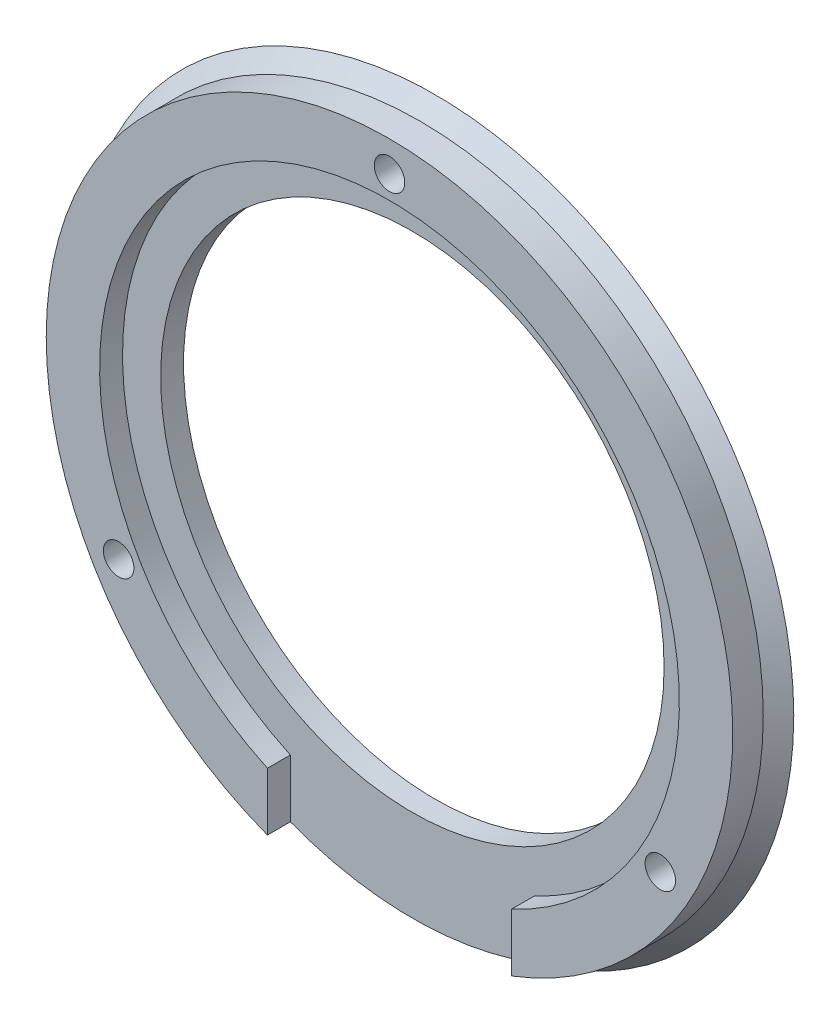
from build123d import *

# Parameters (mm, degrees)
SKETCH_1_R          = 25
SKETCH_1_R_2        = 16.5
EXTRUDE_1_DEPTH     = 3
SKETCH_2_R          = 19
CUT_EXTRUDE_1_DEPTH = 1.5
CUT_EXTRUDE_2_DEPTH = 1.5
SKETCH_4_R          = 1
CUT_EXTRUDE_3_DEPTH = 31.5
SKETCH_6_R          = 1.5
CUT_EXTRUDE_4_DEPTH = 1


with BuildPart() as part:
    # 草图1 → 凸台-拉伸1 (new body)
    with BuildSketch(Plane.XY):
        Circle(SKETCH_1_R)
        Circle(SKETCH_1_R_2, mode=Mode.SUBTRACT)
    extrude(amount=EXTRUDE_1_DEPTH)

    # 草图2 → 切除-拉伸1 (cut)
    with BuildSketch(Plane.XY.offset(3)):
        Circle(SKETCH_2_R)
    extrude(amount=-CUT_EXTRUDE_1_DEPTH, mode=Mode.SUBTRACT)

    # 草图3 → 切除-拉伸2 (cut)
    with BuildSketch(Plane.XY.offset(3)):
        Polygon((0, -29.98623759), (8, -29.98623759), (8, -6.378834071), (-8, -6.378834071), (-8, -29.98623759), align=None)
    extrude(amount=-CUT_EXTRUDE_2_DEPTH, mode=Mode.SUBTRACT)

    # 草图4 → 切除-拉伸3 (cut)
    with BuildSketch(Plane.XY.offset(3)):
        with Locations((0, 20.5)):
            Circle(SKETCH_4_R)
        with Locations((17.753520778, -10.25)):
            Circle(SKETCH_4_R)
        with Locations((-17.753520778, -10.25)):
            Circle(SKETCH_4_R)
    extrude(amount=-CUT_EXTRUDE_3_DEPTH, mode=Mode.SUBTRACT)

    # 草图6 → 切除-拉伸4 (cut)
    with BuildSketch(Plane(origin=(0, 0, 0), x_dir=(-1, 0, 0), z_dir=(0, 0, -1))):
        with Locations((0, 20.5)):
            Circle(SKETCH_6_R)
        with Locations((17.753520778, -10.25)):
            Circle(SKETCH_6_R)
        with Locations((-17.753520778, -10.25)):
            Circle(SKETCH_6_R)
    extrude(amount=-CUT_EXTRUDE_4_DEPTH, mode=Mode.SUBTRACT)

    # 草图8 → 切除-旋转1 (revolve, cut)
    with BuildSketch(Plane(origin=(0, 0, 0), x_dir=(1, 0, 0), z_dir=(0, 1, 0))):
        Polygon((-22.5, -1), (-22.5, -3), (-22.5, -4.221155356), (-26.330731104, -4.221155356), (-26.330731104, -3), (-26.330731104, 1.037990449), (-24, 1.037990449), (-23.5, 1.037990449), (-23.5, 0), align=None)
    revolve(axis=Axis((0, 0, 0), (0, 0, 1)), mode=Mode.SUBTRACT)


solid = part.part
